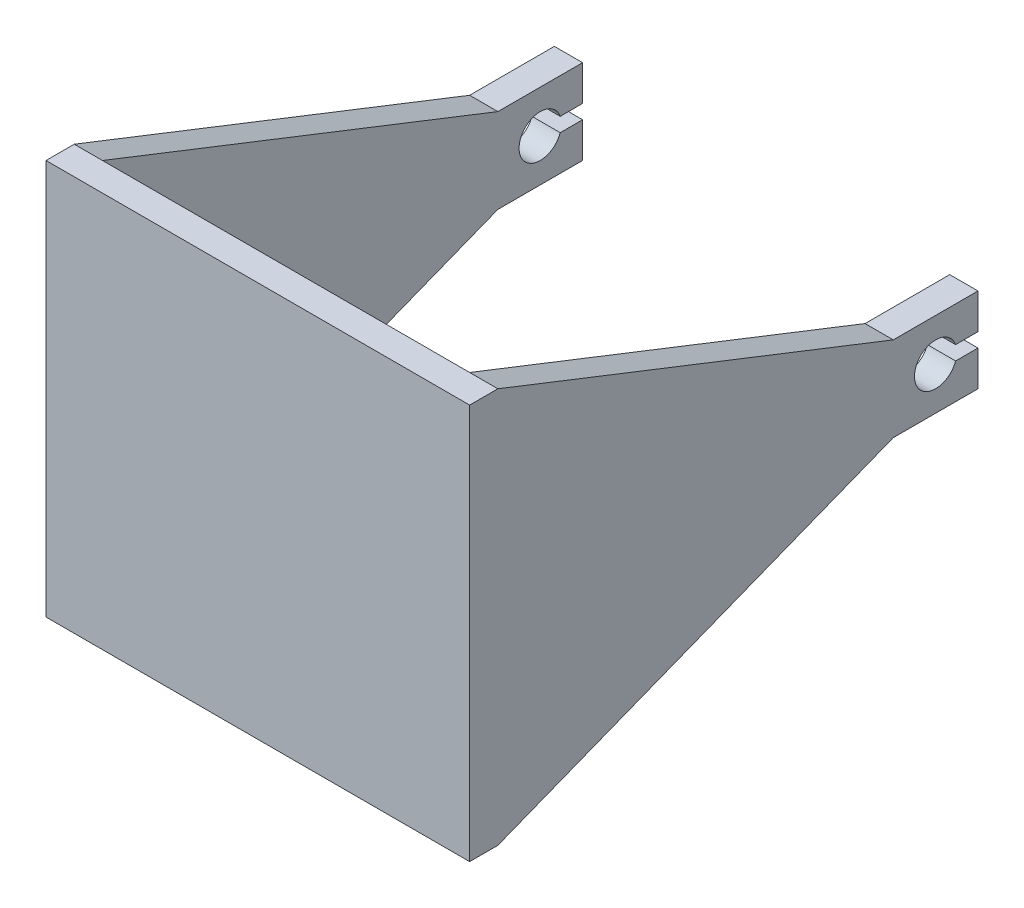
from build123d import *

# Parameters (mm, degrees)
SKETCH1_W               = 150
SKETCH1_H               = 140
SKETCH1_W_2             = 130
SKETCH1_H_2             = 120
BOSS_EXTRUDE1_DEPTH     = 150
BOSS_EXTRUDE2_DEPTH     = 10
BOSS_EXTRUDE3_DEPTH     = 10
SKETCH7_W               = 130
SKETCH7_H               = 150
CUT_EXTRUDE2_DEPTH      = 140
SKETCH8_W               = 10
SKETCH8_H               = 140
BOSS_EXTRUDE4_DEPTH     = 150
CUT_EXTRUDE3_DEPTH      = 1
CUT_EXTRUDE3_DEPTH_BACK = 150


with BuildPart() as part:
    # Sketch1 → Boss-Extrude1 (new body)
    with BuildSketch(Plane.XY):
        Rectangle(SKETCH1_W, SKETCH1_H)
        Rectangle(SKETCH1_W_2, SKETCH1_H_2, mode=Mode.SUBTRACT)
    extrude(amount=BOSS_EXTRUDE1_DEPTH)

    # Sketch3 → Boss-Extrude2 (add)
    with BuildSketch(Plane(origin=(75, 0, 0), x_dir=(0, 0, -1), z_dir=(1, 0, 0))):
        with BuildLine():
            Line((30, 15), (0, 15))
            Line((0, 15), (0, -15))
            Line((0, -15), (30, -15))
            Line((30, -15), (30, -2.5))
            Line((30, -2.5), (22.071067812, -2.5))
            ThreePointArc((22.071067812, -2.5), (7.5, 0), (22.071067812, 2.5))
            Line((22.071067812, 2.5), (30, 2.5))
            Line((30, 2.5), (30, 15))
        make_face()
    extrude(amount=-BOSS_EXTRUDE2_DEPTH)

    # Sketch4 → Boss-Extrude3 (add)
    with BuildSketch(Plane.ZY.offset(75)):
        with BuildLine():
            Line((0, -15), (0, 15))
            Line((0, 15), (-30, 15))
            Line((-30, 15), (-30, 2.5))
            Line((-30, 2.5), (-22.071067812, 2.5))
            ThreePointArc((-22.071067812, 2.5), (-13.73173516, 7.391989197), (-7.5, 0))
            ThreePointArc((-7.5, 0), (-13.73173516, -7.391989197), (-22.071067812, -2.5))
            Line((-22.071067812, -2.5), (-30, -2.5))
            Line((-30, -2.5), (-30, -15))
            Line((-30, -15), (0, -15))
        make_face()
    extrude(amount=-BOSS_EXTRUDE3_DEPTH)

    # Sketch7 → Cut-Extrude2 (cut)
    with BuildSketch(Plane.XZ.offset(70)):
        with Locations((0, 75)):
            Rectangle(SKETCH7_W, SKETCH7_H)
    extrude(amount=-CUT_EXTRUDE2_DEPTH, mode=Mode.SUBTRACT)

    # Sketch8 → Boss-Extrude4 (add)
    with BuildSketch(Plane.ZY.offset(75)):
        with Locations((145, 0)):
            Rectangle(SKETCH8_W, SKETCH8_H)
    extrude(amount=-BOSS_EXTRUDE4_DEPTH)

    # Sketch9 → Cut-Extrude3 (cut, two sides)
    with BuildSketch(Plane.ZY.offset(75)) as cut_extrude3_sk:
        Polygon((0, -15), (140, -70), (0, -70), align=None)
        Polygon((0, 15), (0, 70), (140, 70), align=None)
    extrude(amount=CUT_EXTRUDE3_DEPTH, mode=Mode.SUBTRACT)
    extrude(cut_extrude3_sk.sketch, amount=-CUT_EXTRUDE3_DEPTH_BACK, mode=Mode.SUBTRACT)


solid = part.part
